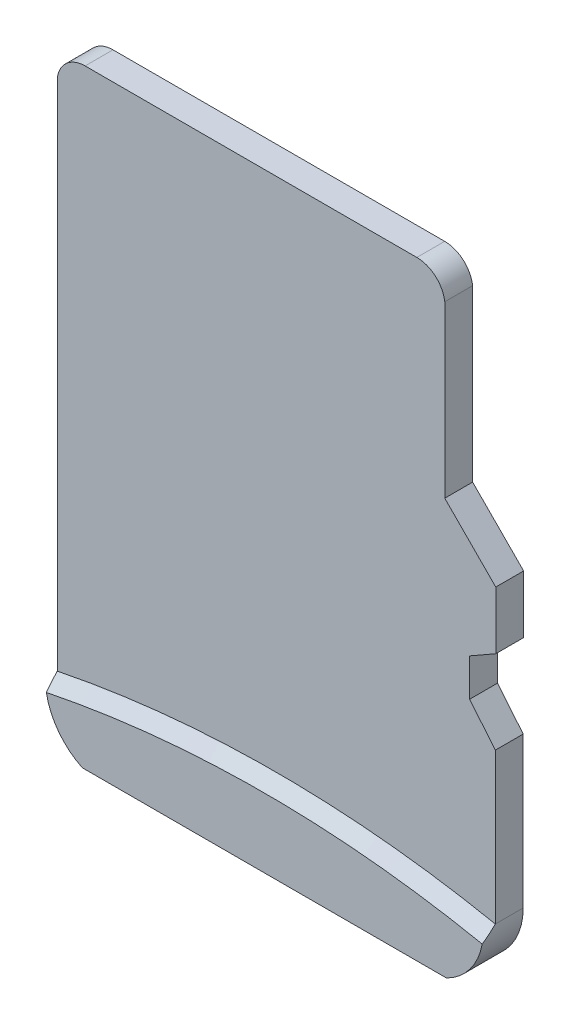
from build123d import *

# Parameters (mm, degrees)
EXTRUDE1_DEPTH = 0.7
EXTRUDE2_DEPTH = 1
DRAFT1_ANGLE   = 45


with BuildPart() as part:
    # Sketch1 → Extrude1 (new body)
    with BuildSketch(Plane.XY):
        with BuildLine():
            Line((19.155576725, 24.033479545), (19.153057259, 24.033479546))
            ThreePointArc((19.153057259, 24.033479546), (18.688120429, 23.858493389), (18.453932737, 23.42038092))
            Line((18.453932737, 23.42038092), (18.453932737, 10.52156184))
            ThreePointArc((18.453932737, 10.52156184), (23.954511515, 11.07234739), (29.455090293, 10.52156184))
            Line((29.455090293, 10.52156184), (29.455090293, 14.303453829))
            Line((29.455090293, 14.303453829), (28.809678981, 15.087349513))
            Line((28.809678981, 15.087349513), (28.809678981, 16.030799168))
            Line((28.809678981, 16.030799168), (29.465965334, 16.405404217))
            Line((29.465965334, 16.405404217), (29.465965334, 17.856041137))
            Line((29.465965334, 17.856041137), (28.185089103, 19.147527308))
            Line((28.185089103, 19.147527308), (28.185089103, 23.42038092))
            ThreePointArc((28.185089103, 23.42038092), (27.949953539, 23.859323131), (27.483445115, 24.033475046))
            Line((27.483445115, 24.033475046), (19.155576725, 24.033479545))
        make_face()
        with BuildLine():
            Line((19.382079549, 9.033491555), (28.526943481, 9.033491554))
            ThreePointArc((28.526943481, 9.033491554), (29.202633724, 9.645535961), (29.455090293, 10.52156184))
            ThreePointArc((29.455090293, 10.52156184), (23.954511515, 11.07234739), (18.453932737, 10.52156184))
            ThreePointArc((18.453932737, 10.52156184), (18.702527644, 9.643127345), (19.382079549, 9.033491555))
        make_face()
    extrude(amount=EXTRUDE1_DEPTH)

    # Sketch2 → Extrude2 (add)
    with BuildSketch(Plane.XY):
        with BuildLine():
            Line((19.382079549, 9.033491555), (28.526943481, 9.033491554))
            ThreePointArc((28.526943481, 9.033491554), (29.202633724, 9.645535961), (29.455090293, 10.52156184))
            ThreePointArc((29.455090293, 10.52156184), (23.954511515, 11.072347393), (18.453932737, 10.52156184))
            ThreePointArc((18.453932737, 10.52156184), (18.702527644, 9.643127345), (19.382079549, 9.033491555))
        make_face()
    extrude(amount=EXTRUDE2_DEPTH)

    # Draft1
    draft1_faces = [part.faces().sort_by_distance(p)[0] for p in [
        (23.954511515, 11.072347393, 0.85),
    ]]
    draft(draft1_faces, Plane(origin=(23.959933723, 1.918279908, 0.7), x_dir=(1, 0, 0), z_dir=(0, 0, 1)), DRAFT1_ANGLE)


solid = part.part
